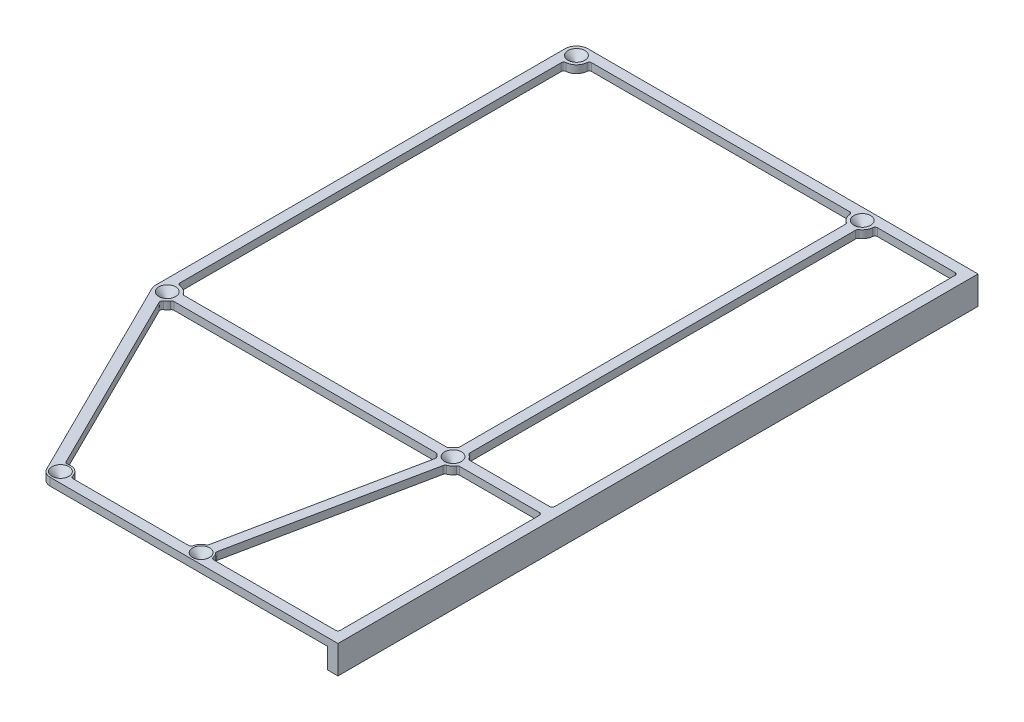
from build123d import *

# Parameters (mm, degrees)
SKETCH2_R           = 0.5
BOSS_EXTRUDE1_DEPTH = 3
SKETCH3_W           = 4
SKETCH3_H           = 250.248923326
BOSS_EXTRUDE2_DEPTH = 8
CHAMFER1_SIZE       = 2.8
FILLET1_R           = 1


with BuildPart() as part:
    # Sketch2 → Boss-Extrude1 (new body)
    with BuildSketch(Plane(origin=(0, 0, 0), x_dir=(1, 0, 0), z_dir=(0, 1, 0))):
        with BuildLine():
            Line((4, -250.248923326), (4, 0))
            Line((4, 0), (0, 0))
            Line((0, 0), (-148.5, 0))
            ThreePointArc((-148.5, 0), (-151.681980515, -1.318019485), (-153, -4.5))
            Line((-153, -4.5), (-153, -164.5))
            ThreePointArc((-153, -164.5), (-152.88121444, -165.527112473), (-152.531128874, -166.5))
            Line((-152.531128874, -166.5), (-112.082261174, -248.027299256))
            ThreePointArc((-112.082261174, -248.027299256), (-110.60761765, -249.648431345), (-108.5, -250.248923326))
            Line((-108.5, -250.248923326), (4, -250.248923326))
        make_face()
        with Locations((-148.5, -4.5)):
            Circle(SKETCH2_R, mode=Mode.SUBTRACT)
        with Locations((-36.75, -4.5)):
            Circle(SKETCH2_R, mode=Mode.SUBTRACT)
        with Locations((-36.75, -164.5)):
            Circle(SKETCH2_R, mode=Mode.SUBTRACT)
        with Locations((-148.5, -164.5)):
            Circle(SKETCH2_R, mode=Mode.SUBTRACT)
        with Locations((-108.5, -246.25)):
            Circle(SKETCH2_R, mode=Mode.SUBTRACT)
        with Locations((-53.5, -246.25)):
            Circle(SKETCH2_R, mode=Mode.SUBTRACT)
        with BuildLine():
            Line((0, -4), (0, -162.5))
            Line((0, -162.5), (-32.718871126, -162.5))
            ThreePointArc((-32.718871126, -162.5), (-33.568019485, -161.318019485), (-34.75, -160.468871126))
            Line((-34.75, -160.468871126), (-34.75, -8.531128874))
            ThreePointArc((-34.75, -8.531128874), (-32.799693914, -6.655245189), (-32.277864045, -4))
            Line((-32.277864045, -4), (0, -4))
        make_face(mode=Mode.SUBTRACT)
        with BuildLine():
            Line((-144.027864045, -4), (-41.222135955, -4))
            ThreePointArc((-41.222135955, -4), (-40.700306086, -6.655245189), (-38.75, -8.531128874))
            Line((-38.75, -8.531128874), (-38.75, -160.468871126))
            ThreePointArc((-38.75, -160.468871126), (-39.931980515, -161.318019485), (-40.781128874, -162.5))
            Line((-40.781128874, -162.5), (-144.468871126, -162.5))
            ThreePointArc((-144.468871126, -162.5), (-146.344754811, -160.549693914), (-149, -160.027864045))
            Line((-149, -160.027864045), (-149, -8.972135955))
            ThreePointArc((-149, -8.972135955), (-145.318019485, -7.681980515), (-144.027864045, -4))
        make_face(mode=Mode.SUBTRACT)
        with BuildLine():
            Line((-32.718871126, -166.5), (0, -166.5))
            Line((0, -166.5), (0, -246.248923326))
            Line((0, -246.248923326), (-49.501076819, -246.248923326))
            ThreePointArc((-49.501076819, -246.248923326), (-49.852891921, -244.609880972), (-50.845628636, -243.25906362))
            Line((-50.845628636, -243.25906362), (-35.599844174, -168.850533482))
            ThreePointArc((-35.599844174, -168.850533482), (-33.905236442, -167.986734905), (-32.718871126, -166.5))
        make_face(mode=Mode.SUBTRACT)
        with BuildLine():
            Line((-146.960287228, -168.728390306), (-110.2763347, -242.667260434))
            ThreePointArc((-110.2763347, -242.667260434), (-106.39238235, -242.851568655), (-104.501076819, -246.248923326))
            Line((-104.501076819, -246.248923326), (-57.498923181, -246.248923326))
            ThreePointArc((-57.498923181, -246.248923326), (-56.743672678, -243.911202162), (-54.764220792, -242.456171649))
            Line((-54.764220792, -242.456171649), (-39.518436329, -168.047641511))
            ThreePointArc((-39.518436329, -168.047641511), (-40.236734905, -167.344763558), (-40.781128874, -166.5))
            Line((-40.781128874, -166.5), (-144.468871126, -166.5))
            ThreePointArc((-144.468871126, -166.5), (-145.5, -167.854101966), (-146.960287228, -168.728390306))
        make_face(mode=Mode.SUBTRACT)
    extrude(amount=BOSS_EXTRUDE1_DEPTH)

    # Sketch3 → Boss-Extrude2 (add)
    with BuildSketch(Plane.XZ):
        with Locations((2, 125.124461663)):
            Rectangle(SKETCH3_W, SKETCH3_H)
    extrude(amount=BOSS_EXTRUDE2_DEPTH)

    # Chamfer1
    chamfer1_edges = [part.edges().sort_by_distance(p)[0] for p in [
        (-109, 3, 246.25),
        (-54, 3, 246.25),
        (-149, 3, 4.5),
        (-37.25, 3, 4.5),
        (-37.25, 3, 164.5),
        (-149, 3, 164.5),
    ]]
    chamfer(chamfer1_edges, length=CHAMFER1_SIZE)

    # Fillet1
    fillet1_edges = [part.edges().sort_by_distance(p)[0] for p in [
        (-32.718871126, 1.5, 166.5),
        (-35.599844174, 1.5, 168.850533482),
        (-50.845628636, 1.5, 243.25906362),
        (-49.501076819, 1.5, 246.248923326),
        (0, 1.5, 246.248923326),
        (0, 1.5, 166.5),
        (-32.277864045, 1.5, 4),
        (-34.75, 1.5, 8.531128874),
        (-34.75, 1.5, 160.468871126),
        (-32.718871126, 1.5, 162.5),
        (0, 1.5, 162.5),
        (0, 1.5, 4),
        (-144.027864045, 1.5, 4),
        (-149, 1.5, 8.972135955),
        (-149, 1.5, 160.027864045),
        (-144.468871126, 1.5, 162.5),
        (-40.781128874, 1.5, 162.5),
        (-38.75, 1.5, 160.468871126),
        (-38.75, 1.5, 8.531128874),
        (-41.222135955, 1.5, 4),
        (-57.498923181, 1.5, 246.248923326),
        (-54.764220792, 1.5, 242.456171649),
        (-39.518436329, 1.5, 168.047641511),
        (-40.781128874, 1.5, 166.5),
        (-144.468871126, 1.5, 166.5),
        (-146.960287228, 1.5, 168.728390306),
        (-110.2763347, 1.5, 242.667260434),
        (-104.501076819, 1.5, 246.248923326),
    ]]
    fillet(fillet1_edges, radius=FILLET1_R)


solid = part.part
